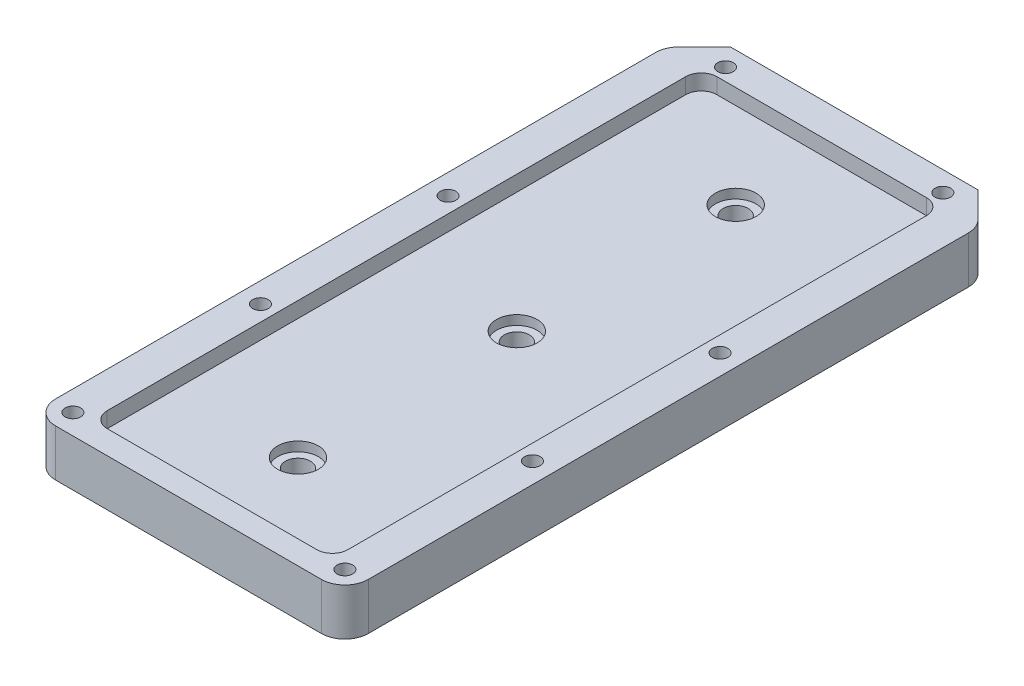
from build123d import *

# Parameters (mm, degrees)
SKETCH1_R           = 2.5
SKETCH1_R_2         = 4
BOSS_EXTRUDE1_DEPTH = 15
SKETCH2_R           = 6.5
CUT_EXTRUDE1_DEPTH  = 8
FILLET1_R           = 7.5
CUT_EXTRUDE2_DEPTH  = 5
SKETCH5_W           = 82.5
SKETCH5_H           = 15.853105066
CUT_EXTRUDE3_DEPTH  = 15
CUT_EXTRUDE4_DEPTH  = 5
SKETCH7_R           = 2.5
BOSS_EXTRUDE2_DEPTH = 0.4


with BuildPart() as part:
    # Sketch1 → Boss-Extrude1 (new body)
    with BuildSketch(Plane(origin=(0, 0, 0), x_dir=(1, 0, 0), z_dir=(0, 1, 0))):
        Polygon((39.925742574, 57.194719472), (57.425742574, 39.694719472), (57.425742574, -162.805280528), (-42.574257426, -162.805280528), (-42.574257426, 39.694719472), (-25.074257426, 57.194719472), align=None)
        with Locations((42.175742574, 43.694719472)):
            Circle(SKETCH1_R, mode=Mode.SUBTRACT)
        with Locations((-27.324257426, 43.694719472)):
            Circle(SKETCH1_R, mode=Mode.SUBTRACT)
        with Locations((50.925742574, -36.305280528)):
            Circle(SKETCH1_R, mode=Mode.SUBTRACT)
        with Locations((-36.074257426, -36.305280528)):
            Circle(SKETCH1_R, mode=Mode.SUBTRACT)
        with Locations((50.925742574, -96.305280528)):
            Circle(SKETCH1_R, mode=Mode.SUBTRACT)
        with Locations((-36.074257426, -96.305280528)):
            Circle(SKETCH1_R, mode=Mode.SUBTRACT)
        with Locations((50.925742574, -156.305280528)):
            Circle(SKETCH1_R, mode=Mode.SUBTRACT)
        with Locations((-36.074257426, -156.305280528)):
            Circle(SKETCH1_R, mode=Mode.SUBTRACT)
        with Locations((7.425742574, -127.805280528)):
            Circle(SKETCH1_R_2, mode=Mode.SUBTRACT)
        with Locations((7.425742574, -57.805280528)):
            Circle(SKETCH1_R_2, mode=Mode.SUBTRACT)
        with Locations((7.425742574, 12.194719472)):
            Circle(SKETCH1_R_2, mode=Mode.SUBTRACT)
    extrude(amount=BOSS_EXTRUDE1_DEPTH)

    # Sketch2 → Cut-Extrude1 (cut)
    with BuildSketch(Plane(origin=(0, 15, 0), x_dir=(1, 0, 0), z_dir=(0, 1, 0))):
        with Locations((7.425742574, 12.194719472)):
            Circle(SKETCH2_R)
        with Locations((7.425742574, -57.805280528)):
            Circle(SKETCH2_R)
        with Locations((7.425742574, -127.805280528)):
            Circle(SKETCH2_R)
    extrude(amount=-CUT_EXTRUDE1_DEPTH, mode=Mode.SUBTRACT)

    # Fillet1
    fillet1_edges = [part.edges().sort_by_distance(p)[0] for p in [
        (57.425742574, 7.5, -39.694719472),
        (57.425742574, 7.5, 162.805280528),
        (-42.574257426, 7.5, 162.805280528),
        (-42.574257426, 7.5, -39.694719472),
        (-25.074257426, 7.5, -57.194719472),
        (39.925742574, 7.5, -57.194719472),
    ]]
    fillet(fillet1_edges, radius=FILLET1_R)

    # Sketch4 → Cut-Extrude2 (cut)
    with BuildSketch(Plane(origin=(0, 15, 0), x_dir=(1, 0, 0), z_dir=(0, 1, 0))):
        with BuildLine():
            Line((-26.074257426, -155.305280528), (40.925742574, -155.305280528))
            ThreePointArc((40.925742574, -155.305280528), (44.46127648, -153.840814434), (45.925742574, -150.305280528))
            Line((45.925742574, -150.305280528), (45.925742574, 34.694719472))
            ThreePointArc((45.925742574, 34.694719472), (44.46127648, 38.230253378), (40.925742574, 39.694719472))
            Line((40.925742574, 39.694719472), (-26.074257426, 39.694719472))
            ThreePointArc((-26.074257426, 39.694719472), (-29.609791332, 38.230253378), (-31.074257426, 34.694719472))
            Line((-31.074257426, 34.694719472), (-31.074257426, -150.305280528))
            ThreePointArc((-31.074257426, -150.305280528), (-29.609791332, -153.840814434), (-26.074257426, -155.305280528))
        make_face()
    extrude(amount=-CUT_EXTRUDE2_DEPTH, mode=Mode.SUBTRACT)

    # Sketch5 → Cut-Extrude3 (cut)
    with BuildSketch(Plane(origin=(0, 15, 0), x_dir=(1, 0, 0), z_dir=(0, 1, 0))):
        with Locations((7.425742574, 58.018166939)):
            Rectangle(SKETCH5_W, SKETCH5_H)
    extrude(amount=-CUT_EXTRUDE3_DEPTH, mode=Mode.SUBTRACT)

    # Sketch6 → Cut-Extrude4 (cut)
    with BuildSketch(Plane.XZ):
        Polygon((-38.441393529, 32.205280528), (-33.707121322, 32.205280528), (-31.339985218, 36.305280528), (-33.707121322, 40.405280528), (-38.441393529, 40.405280528), (-40.808529633, 36.305280528), align=None)
        Polygon((55.660014782, 36.305280528), (53.292878678, 40.405280528), (48.558606471, 40.405280528), (46.191470367, 36.305280528), (48.558606471, 32.205280528), (53.292878678, 32.205280528), align=None)
        Polygon((-22.589985218, -43.694719472), (-24.957121322, -39.594719472), (-29.691393529, -39.594719472), (-32.058529633, -43.694719472), (-29.691393529, -47.794719472), (-24.957121322, -47.794719472), align=None)
        Polygon((46.910014782, -43.694719472), (44.542878678, -39.594719472), (39.808606471, -39.594719472), (37.441470367, -43.694719472), (39.808606471, -47.794719472), (44.542878678, -47.794719472), align=None)
        Polygon((-31.339985218, 96.305280528), (-33.707121322, 100.405280528), (-38.441393529, 100.405280528), (-40.808529633, 96.305280528), (-38.441393529, 92.205280528), (-33.707121322, 92.205280528), align=None)
        Polygon((55.660014782, 96.305280528), (53.292878678, 100.405280528), (48.558606471, 100.405280528), (46.191470367, 96.305280528), (48.558606471, 92.205280528), (53.292878678, 92.205280528), align=None)
        Polygon((55.660014782, 156.305280528), (53.292878678, 160.405280528), (48.558606471, 160.405280528), (46.191470367, 156.305280528), (48.558606471, 152.205280528), (53.292878678, 152.205280528), align=None)
        Polygon((-40.808529633, 156.305280528), (-38.441393529, 152.205280528), (-33.707121322, 152.205280528), (-31.339985218, 156.305280528), (-33.707121322, 160.405280528), (-38.441393529, 160.405280528), align=None)
    extrude(amount=-CUT_EXTRUDE4_DEPTH, mode=Mode.SUBTRACT)

    # Sketch7 → Boss-Extrude2 (add)
    with BuildSketch(Plane.XZ.offset(-5)):
        with Locations((-36.074257426, 156.305280528)):
            Circle(SKETCH7_R)
        with Locations((50.925742574, 156.305280528)):
            Circle(SKETCH7_R)
        with Locations((-36.074257426, 96.305280528)):
            Circle(SKETCH7_R)
        with Locations((50.925742574, 96.305280528)):
            Circle(SKETCH7_R)
        with Locations((-36.074257426, 36.305280528)):
            Circle(SKETCH7_R)
        with Locations((50.925742574, 36.305280528)):
            Circle(SKETCH7_R)
        with Locations((-27.324257426, -43.694719472)):
            Circle(SKETCH7_R)
        with Locations((42.175742574, -43.694719472)):
            Circle(SKETCH7_R)
    extrude(amount=-BOSS_EXTRUDE2_DEPTH)


solid = part.part
